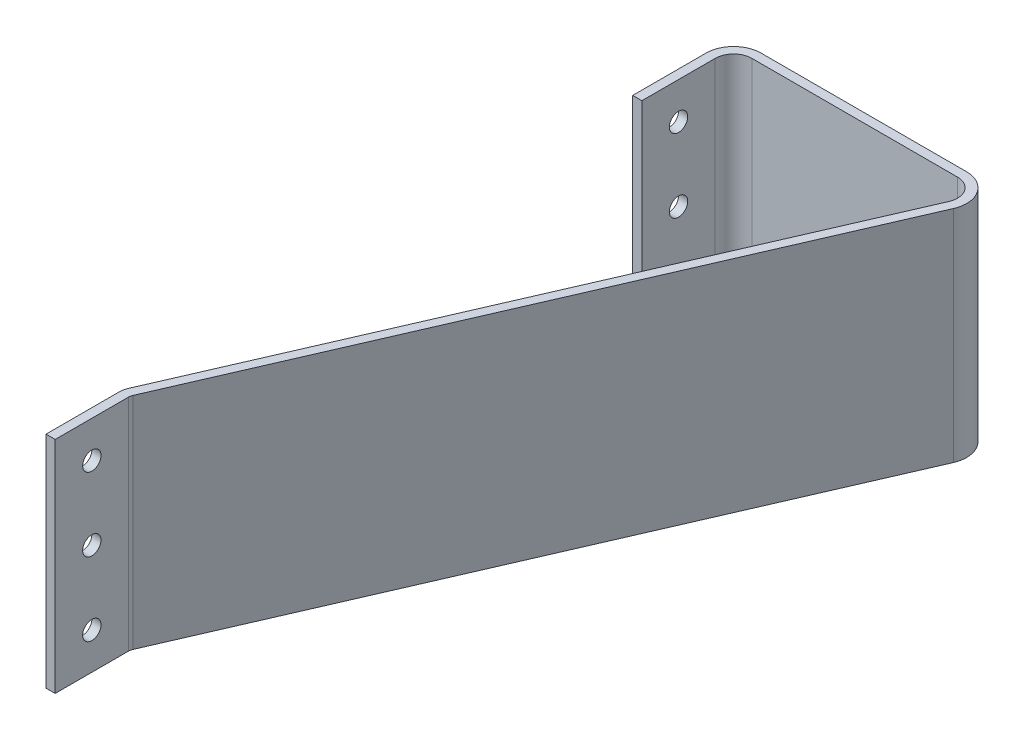
from build123d import *

# Parameters (mm, degrees)
BOSS_EXTRUDE1_DEPTH     = 76.2
SKETCH2_R               = 3.175
CUT_EXTRUDE1_DEPTH      = 88.080358512
CUT_EXTRUDE1_DEPTH_BACK = 4.175
SKETCH4_R               = 3.175
CUT_EXTRUDE3_DEPTH      = 3.175


with BuildPart() as part:
    # Sketch1 → Boss-Extrude1 (new body)
    with BuildSketch(Plane(origin=(0, 0, 0), x_dir=(1, 0, 0), z_dir=(0, 1, 0))):
        with BuildLine():
            Line((-279.4, 0), (-279.4, 25.4))
            ThreePointArc((-279.4, 25.4), (-279.267281416, 26.691476594), (-278.874673451, 27.928968009))
            Line((-278.874673451, 27.928968009), (-192.844968037, 226.071031991))
            ThreePointArc((-192.844968037, 226.071031991), (-193.36014778, 232.083069992), (-198.669641488, 234.95))
            Line((-198.669641488, 234.95), (-269.875, 234.95))
            ThreePointArc((-269.875, 234.95), (-274.365128061, 233.090128061), (-276.225, 228.6))
            Line((-276.225, 228.6), (-276.225, 203.2))
            Line((-276.225, 203.2), (-279.4, 203.2))
            Line((-279.4, 203.2), (-279.4, 228.6))
            ThreePointArc((-279.4, 228.6), (-276.610192091, 235.335192091), (-269.875, 238.125))
            Line((-269.875, 238.125), (-198.669641488, 238.125))
            ThreePointArc((-198.669641488, 238.125), (-190.705400927, 233.824604988), (-189.932631312, 224.806547986))
            Line((-189.932631312, 224.806547986), (-275.962336725, 26.664484005))
            ThreePointArc((-275.962336725, 26.664484005), (-276.158640708, 26.045738297), (-276.225, 25.4))
            Line((-276.225, 25.4), (-276.225, 0))
            Line((-276.225, 0), (-279.4, 0))
        make_face()
    extrude(amount=BOSS_EXTRUDE1_DEPTH)

    # Sketch2 → Cut-Extrude1 (cut, two sides)
    with BuildSketch(Plane(origin=(-276.225, 0, 0), x_dir=(0, 0, -1), z_dir=(1, 0, 0))) as cut_extrude1_sk:
        with Locations((12.7, 63.5)):
            Circle(SKETCH2_R)
        with Locations((12.7, 12.7)):
            Circle(SKETCH2_R)
        with Locations((12.7, 38.1)):
            Circle(SKETCH2_R)
    extrude(amount=CUT_EXTRUDE1_DEPTH, mode=Mode.SUBTRACT)
    extrude(cut_extrude1_sk.sketch, amount=-CUT_EXTRUDE1_DEPTH_BACK, mode=Mode.SUBTRACT)

    # Sketch4 → Cut-Extrude3 (cut)
    with BuildSketch(Plane.ZY.offset(279.4)):
        with Locations((-215.9, 38.1)):
            Circle(SKETCH4_R)
        with Locations((-215.9, 63.5)):
            Circle(SKETCH4_R)
        with Locations((-215.9, 12.7)):
            Circle(SKETCH4_R)
    extrude(amount=-CUT_EXTRUDE3_DEPTH, mode=Mode.SUBTRACT)


solid = part.part
